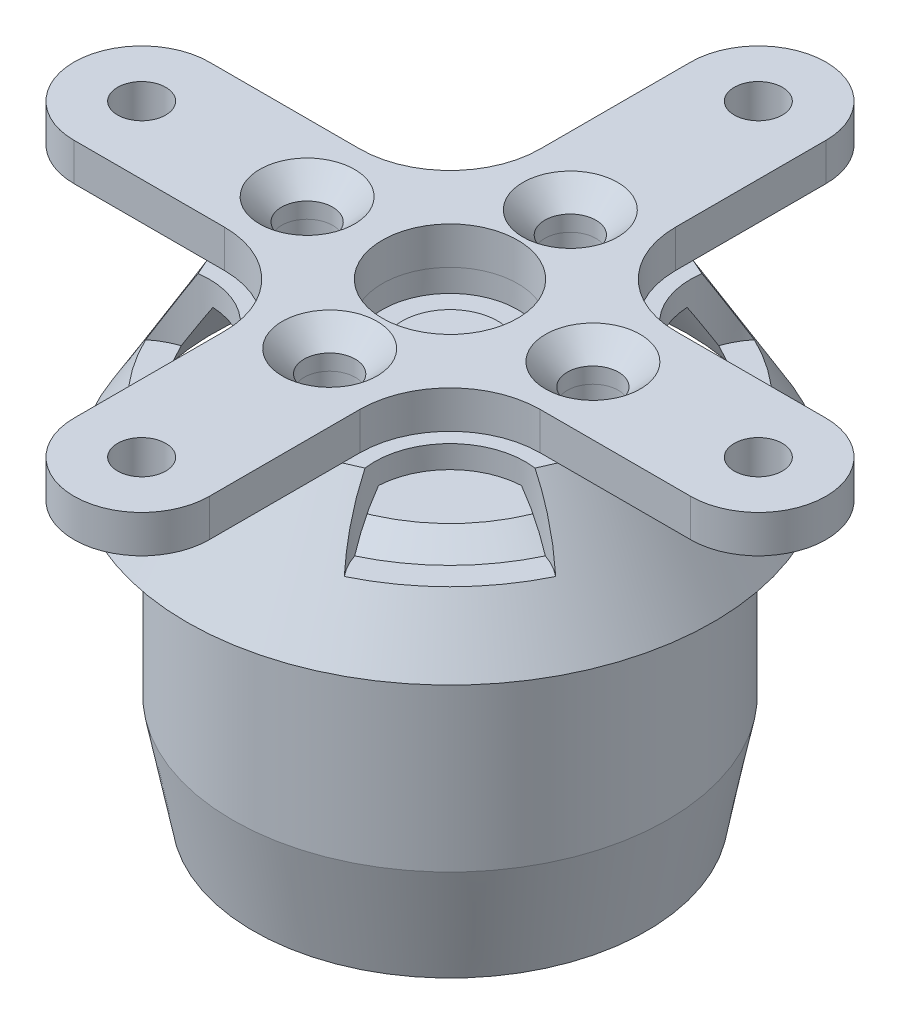
from build123d import *

# Parameters (mm, degrees)
SKETCH2_R                                      = 4.5
SKETCH2_R_2                                    = 1.6
BOSS_EXTRUDE1_DEPTH                            = 2.5
SKETCH4_R                                      = 1.5
CUT_EXTRUDE1_DEPTH                             = 3.5
CUT_EXTRUDE1_DEPTH_BACK                        = 9.5
SKETCH5_R                                      = 5
CUT_EXTRUDE2_DEPTH                             = 4.5
SKETCH7_R                                      = 4.5
CUT_EXTRUDE3_DEPTH                             = 9.5000001
CSK_FOR_M3_FLAT_HEAD_MACHINE_SCREW1_AT_2_COUNT = 2
CSK_FOR_M3_FLAT_HEAD_MACHINE_SCREW1_AT_2_PITCH = 12.419742348
CSK_FOR_M3_FLAT_HEAD_MACHINE_SCREW1_AT_3_COUNT = 2
CSK_FOR_M3_FLAT_HEAD_MACHINE_SCREW1_AT_3_PITCH = 19
CSK_FOR_M3_FLAT_HEAD_MACHINE_SCREW1_AT_4_COUNT = 2
CSK_FOR_M3_FLAT_HEAD_MACHINE_SCREW1_AT_4_PITCH = 12.419742348


with BuildPart() as part:
    # Sketch2 → Boss-Extrude1 (new body)
    with BuildSketch(Plane(origin=(0, 0, 0), x_dir=(1, 0, 0), z_dir=(0, 1, 0))):
        with BuildLine():
            Line((4.5, 20.5), (4.5, 10.5))
            ThreePointArc((4.5, 10.5), (6.257359313, 6.257359313), (10.5, 4.5))
            Line((10.5, 4.5), (20.5, 4.5))
            ThreePointArc((20.5, 4.5), (25, 0), (20.5, -4.5))
            Line((20.5, -4.5), (10.5, -4.5))
            ThreePointArc((10.5, -4.5), (6.257359313, -6.257359313), (4.5, -10.5))
            Line((4.5, -10.5), (4.5, -20.5))
            ThreePointArc((4.5, -20.5), (0, -25), (-4.5, -20.5))
            Line((-4.5, -20.5), (-4.5, -10.5))
            ThreePointArc((-4.5, -10.5), (-6.257359313, -6.257359313), (-10.5, -4.5))
            Line((-10.5, -4.5), (-20.5, -4.5))
            ThreePointArc((-20.5, -4.5), (-25, 0), (-20.5, 4.5))
            Line((-20.5, 4.5), (-10.5, 4.5))
            ThreePointArc((-10.5, 4.5), (-6.257359313, 6.257359313), (-4.5, 10.5))
            Line((-4.5, 10.5), (-4.5, 20.5))
            ThreePointArc((-4.5, 20.5), (0, 25), (4.5, 20.5))
        make_face()
        Circle(SKETCH2_R, mode=Mode.SUBTRACT)
        with Locations((0, 20.5)):
            Circle(SKETCH2_R_2, mode=Mode.SUBTRACT)
        with Locations((20.5, 0)):
            Circle(SKETCH2_R_2, mode=Mode.SUBTRACT)
        with Locations((0, -20.5)):
            Circle(SKETCH2_R_2, mode=Mode.SUBTRACT)
        with Locations((-20.5, 0)):
            Circle(SKETCH2_R_2, mode=Mode.SUBTRACT)
    extrude(amount=BOSS_EXTRUDE1_DEPTH)


with BuildPart() as body_2:
    # Sketch3 → Revolve1 (revolve)
    with BuildSketch(Plane(origin=(0, 0, 0), x_dir=(0, 0, -1), z_dir=(1, 0, 0))):
        Polygon((-17.5, -8.5), (-12.5, 0), (0, 0), (0, -8.5), align=None)
    revolve(axis=Axis((0, 0, 0), (0, -1, 0)))


with BuildPart() as cut_extrude1_tool:
    # Sketch4 → Cut-Extrude1 (new body, two sides)
    with BuildSketch(Plane(origin=(0, 0, 0), x_dir=(1, 0, 0), z_dir=(0, 1, 0))) as cut_extrude1_sk:
        with Locations((0, 8)):
            Circle(SKETCH4_R)
        with Locations((0, -8)):
            Circle(SKETCH4_R)
        with Locations((9.5, 0)):
            Circle(SKETCH4_R)
        with Locations((-9.5, 0)):
            Circle(SKETCH4_R)
    extrude(amount=CUT_EXTRUDE1_DEPTH)
    extrude(cut_extrude1_sk.sketch, amount=-CUT_EXTRUDE1_DEPTH_BACK)


with BuildPart() as part_1:
    add(part.part)

    # Cut-Extrude1: cut by cut_extrude1_tool
    add(cut_extrude1_tool.part, mode=Mode.SUBTRACT)


with BuildPart() as body_2_1:
    add(body_2.part)

    # Cut-Extrude1: cut by cut_extrude1_tool
    add(cut_extrude1_tool.part, mode=Mode.SUBTRACT)

    # Sketch5 → Cut-Extrude2 (cut)
    with BuildSketch(Plane(origin=(0, 0, 0), x_dir=(1, 0, 0), z_dir=(0, 1, 0))):
        with Locations((10.5, 10.5)):
            Circle(SKETCH5_R)
        with Locations((10.5, -10.5)):
            Circle(SKETCH5_R)
        with Locations((-10.5, -10.5)):
            Circle(SKETCH5_R)
        with Locations((-10.5, 10.5)):
            Circle(SKETCH5_R)
    extrude(amount=-CUT_EXTRUDE2_DEPTH, mode=Mode.SUBTRACT)

    # Sketch6 → Cut-Revolve1 (revolve, cut)
    with BuildSketch(Plane(origin=(0, 0, 0), x_dir=(0, 0, -1), z_dir=(1, 0, 0))):
        Polygon((-15.759727977, -8.5), (-11.642080919, -1.5), (0, -1.5), (0, -8.5), align=None)
    revolve(axis=Axis((0, -8.5, 0), (0, 1, 0)), mode=Mode.SUBTRACT)

    # Sketch7 → Cut-Extrude3 (cut, through all)
    with BuildSketch(Plane(origin=(0, 0, 0), x_dir=(1, 0, 0), z_dir=(0, 1, 0))):
        Circle(SKETCH7_R)
    extrude(amount=-CUT_EXTRUDE3_DEPTH, mode=Mode.SUBTRACT)


with BuildPart() as csk_for_m3_flat_head_machine_screw1_tool:
    # Sketch8 → CSK for M3 Flat Head Machine Screw1 (revolve)
    with BuildSketch(Plane(origin=(9.5, 2.5, 0), x_dir=(0, 0, 1), z_dir=(1, 0, 0))):
        Polygon((0, 0), (0, 11), (1.7, 11), (1.7, 1.45), (3.15, 0), align=None)
    csk_for_m3_flat_head_machine_screw1 = revolve(axis=Axis((9.5, 8.85, 0), (0, -1, 0)))


with BuildPart() as part_2:
    add(part_1.part)

    # CSK for M3 Flat Head Machine Screw1: cut by csk_for_m3_flat_head_machine_screw1_tool
    add(csk_for_m3_flat_head_machine_screw1_tool.part, mode=Mode.SUBTRACT)


with BuildPart() as body_2_2:
    add(body_2_1.part)

    # CSK for M3 Flat Head Machine Screw1: cut by csk_for_m3_flat_head_machine_screw1_tool
    add(csk_for_m3_flat_head_machine_screw1_tool.part, mode=Mode.SUBTRACT)


with BuildPart() as csk_for_m3_flat_head_machine_screw1_at_2_tool:
    # CSK for M3 Flat Head Machine Screw1 at 2: CSK for M3 Flat Head Machine Screw1 ×2
    with Locations(*[Vector(-0.764911198, 0, 0.644135746) * (i * CSK_FOR_M3_FLAT_HEAD_MACHINE_SCREW1_AT_2_PITCH) for i in range(1, CSK_FOR_M3_FLAT_HEAD_MACHINE_SCREW1_AT_2_COUNT)]):
        add(csk_for_m3_flat_head_machine_screw1)


with BuildPart() as part_3:
    add(part_2.part)

    # CSK for M3 Flat Head Machine Screw1 at 2: cut by csk_for_m3_flat_head_machine_screw1_at_2_tool
    add(csk_for_m3_flat_head_machine_screw1_at_2_tool.part, mode=Mode.SUBTRACT)


with BuildPart() as body_2_3:
    add(body_2_2.part)

    # CSK for M3 Flat Head Machine Screw1 at 2: cut by csk_for_m3_flat_head_machine_screw1_at_2_tool
    add(csk_for_m3_flat_head_machine_screw1_at_2_tool.part, mode=Mode.SUBTRACT)


with BuildPart() as csk_for_m3_flat_head_machine_screw1_at_3_tool:
    # CSK for M3 Flat Head Machine Screw1 at 3: CSK for M3 Flat Head Machine Screw1 ×2
    with Locations(*[(-i * CSK_FOR_M3_FLAT_HEAD_MACHINE_SCREW1_AT_3_PITCH, 0, 0) for i in range(1, CSK_FOR_M3_FLAT_HEAD_MACHINE_SCREW1_AT_3_COUNT)]):
        add(csk_for_m3_flat_head_machine_screw1)


with BuildPart() as part_4:
    add(part_3.part)

    # CSK for M3 Flat Head Machine Screw1 at 3: cut by csk_for_m3_flat_head_machine_screw1_at_3_tool
    add(csk_for_m3_flat_head_machine_screw1_at_3_tool.part, mode=Mode.SUBTRACT)


with BuildPart() as body_2_4:
    add(body_2_3.part)

    # CSK for M3 Flat Head Machine Screw1 at 3: cut by csk_for_m3_flat_head_machine_screw1_at_3_tool
    add(csk_for_m3_flat_head_machine_screw1_at_3_tool.part, mode=Mode.SUBTRACT)


with BuildPart() as csk_for_m3_flat_head_machine_screw1_at_4_tool:
    # CSK for M3 Flat Head Machine Screw1 at 4: CSK for M3 Flat Head Machine Screw1 ×2
    with Locations(*[Vector(-0.764911198, 0, -0.644135746) * (i * CSK_FOR_M3_FLAT_HEAD_MACHINE_SCREW1_AT_4_PITCH) for i in range(1, CSK_FOR_M3_FLAT_HEAD_MACHINE_SCREW1_AT_4_COUNT)]):
        add(csk_for_m3_flat_head_machine_screw1)


with BuildPart() as part_5:
    add(part_4.part)

    # CSK for M3 Flat Head Machine Screw1 at 4: cut by csk_for_m3_flat_head_machine_screw1_at_4_tool
    add(csk_for_m3_flat_head_machine_screw1_at_4_tool.part, mode=Mode.SUBTRACT)


with BuildPart() as body_2_5:
    add(body_2_4.part)

    # CSK for M3 Flat Head Machine Screw1 at 4: cut by csk_for_m3_flat_head_machine_screw1_at_4_tool
    add(csk_for_m3_flat_head_machine_screw1_at_4_tool.part, mode=Mode.SUBTRACT)


with BuildPart() as body_3:
    # Sketch10 → Revolve2 (revolve)
    with BuildSketch(Plane.XY):
        Polygon((0, -1.5), (3.182512776, -1.5), (3.182512776, -4.5), (10, -4.5), (14.454603177, -8.068170721), (14.454603177, -21.416270618), (13.070873795, -28.5), (0, -28.5), align=None)
    revolve(axis=Axis((0, -1.5, 0), (0, -1, 0)))


solid = Compound([part_5.part, body_2_5.part, body_3.part])
